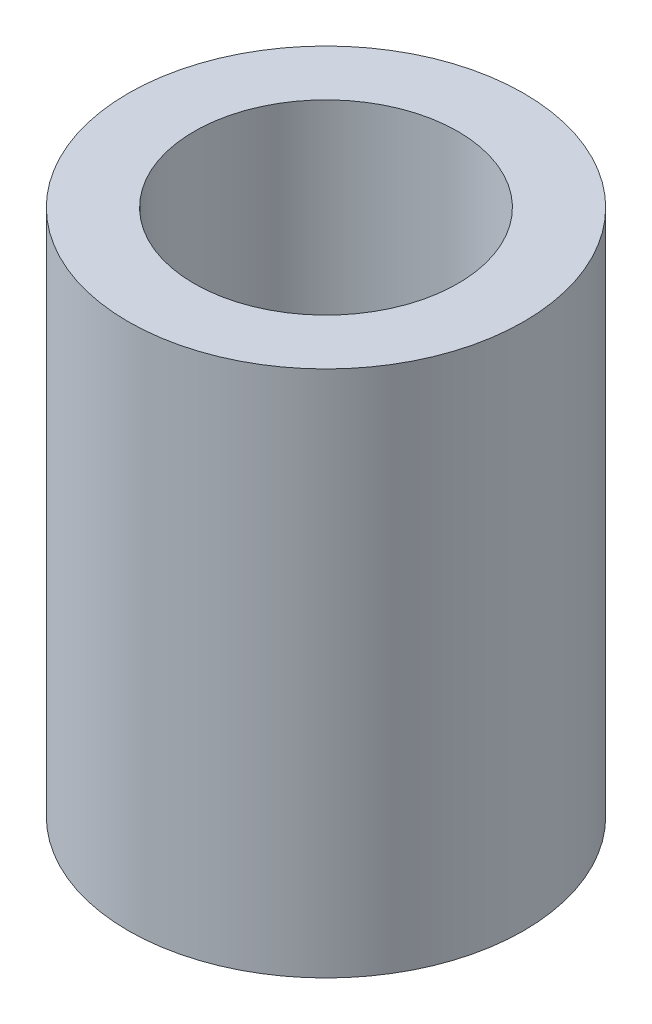
from build123d import *

# Parameters (mm, degrees)
SKETCH1_R           = 6
SKETCH1_R_2         = 4
BOSS_EXTRUDE1_DEPTH = 16


with BuildPart() as part:
    # Sketch1 → Boss-Extrude1 (new body)
    with BuildSketch(Plane(origin=(0, 0, 0), x_dir=(1, 0, 0), z_dir=(0, 1, 0))):
        Circle(SKETCH1_R)
        Circle(SKETCH1_R_2, mode=Mode.SUBTRACT)
    extrude(amount=BOSS_EXTRUDE1_DEPTH)


solid = part.part
